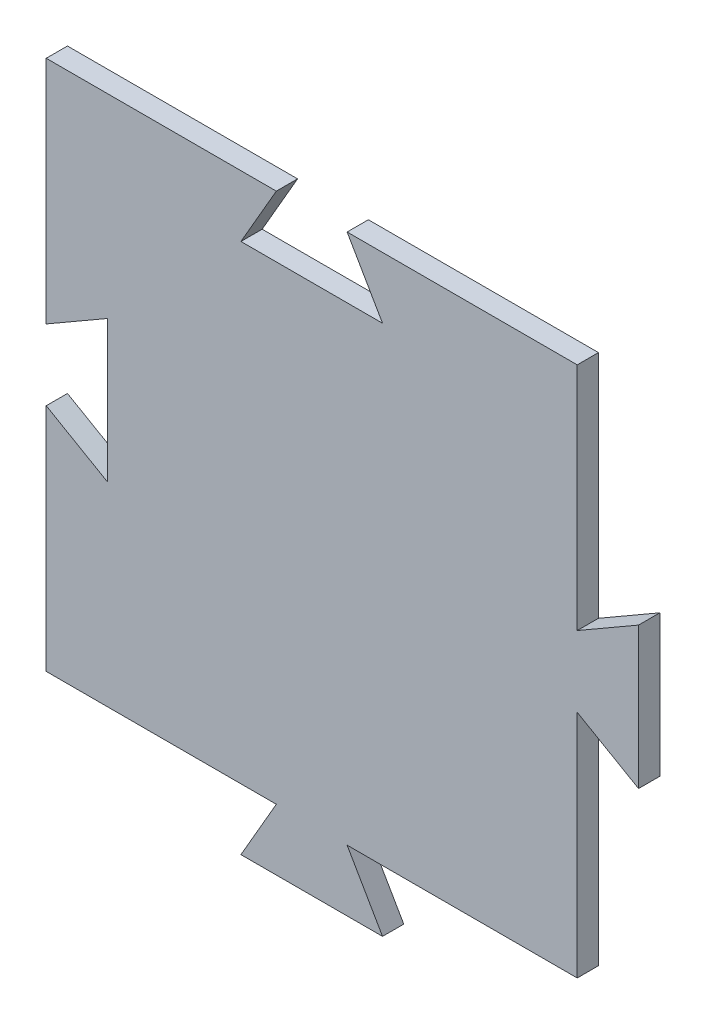
from build123d import *

# Parameters (mm, degrees)
BOSS_EXTRU_1_DEPTH = 6


with BuildPart() as part:
    # Esquisse1 → Boss.-Extru.1 (new body)
    with BuildSketch(Plane.XY):
        Polygon((-89.948090186, -21.608395358), (-49.948090186, -21.608395358), (-59.948093565, -4.287889233), (5.051906435, -4.287889233), (5.051906435, 60.712110767), (22.372416462, 50.712114146), (22.372416462, 90.712114146), (5.051910337, 80.712110767), (5.051910337, 145.712110767), (-59.948089663, 145.712110767), (-49.948086283, 128.391604642), (-89.948086283, 128.391604642), (-79.948089663, 145.712114669), (-144.948089663, 145.712114669), (-144.948089663, 80.712114669), (-127.627583538, 90.712118048), (-127.627583538, 50.712118048), (-144.948093565, 60.712114669), (-144.948093565, -4.287885331), (-79.948093565, -4.287885331), align=None)
    extrude(amount=BOSS_EXTRU_1_DEPTH)


solid = part.part
